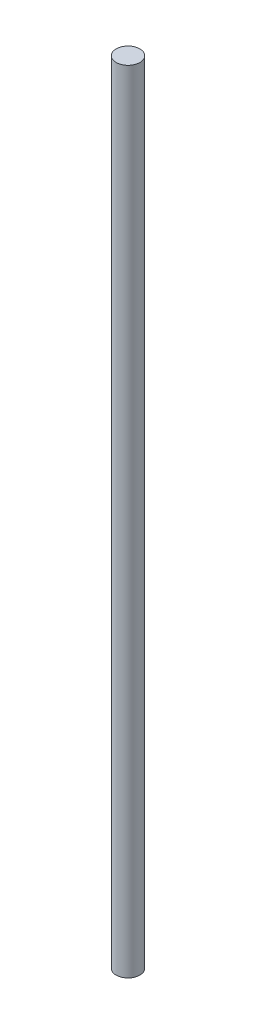
from build123d import *

# Parameters (mm, degrees)
SKETCH1_R           = 1.5
BOSS_EXTRUDE1_DEPTH = 100.1


with BuildPart() as part:
    # Sketch1 → Boss-Extrude1 (new body)
    with BuildSketch(Plane(origin=(0, 0, 0), x_dir=(1, 0, 0), z_dir=(0, 1, 0))):
        Circle(SKETCH1_R)
    extrude(amount=BOSS_EXTRUDE1_DEPTH)


solid = part.part
